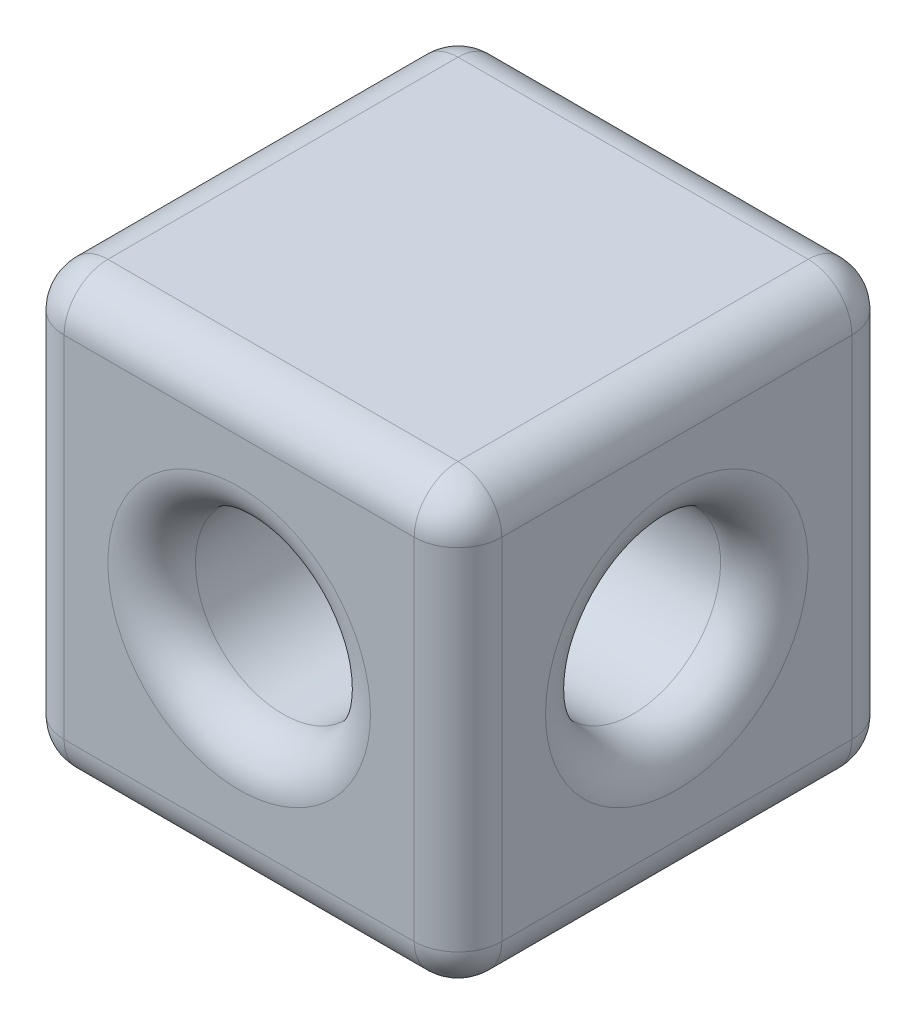
from build123d import *

# Parameters (mm, degrees)
ESQUISSE1_W             = 5
ESQUISSE1_H             = 5
ESQUISSE1_R             = 1
BOSS_EXTRU_1_DEPTH      = 5
ESQUISSE2_R             = 1
ENL_V_MAT_EXTRU_1_DEPTH = 10
CONG_1_R                = 0.5


with BuildPart() as part:
    # Esquisse1 → Boss.-Extru.1 (new body)
    with BuildSketch(Plane.XY):
        Rectangle(ESQUISSE1_W, ESQUISSE1_H)
        Circle(ESQUISSE1_R, mode=Mode.SUBTRACT)
    extrude(amount=BOSS_EXTRU_1_DEPTH)

    # Esquisse2 → Enlèv. mat.-Extru.1 (cut)
    with BuildSketch(Plane(origin=(2.5, 0, 0), x_dir=(0, 0, -1), z_dir=(1, 0, 0))):
        with Locations((-2.5, 0)):
            Circle(ESQUISSE2_R)
    extrude(amount=-ENL_V_MAT_EXTRU_1_DEPTH, mode=Mode.SUBTRACT)

    # Congé1
    cong_1_edges = [part.edges().sort_by_distance(p)[0] for p in [
        (-2.5, 0, 5),
        (-1, 0, 0),
        (-1, 0, 5),
        (0, -2.5, 5),
        (-2.5, 0, 3.5),
        (2.5, 0, 3.5),
        (2.5, 0, 5),
        (0, -2.5, 0),
        (-2.5, 0, 0),
        (0, 2.5, 0),
        (2.5, 0, 0),
        (0, 2.5, 5),
        (2.5, -2.5, 2.5),
        (-2.5, -2.5, 2.5),
        (-2.5, 2.5, 2.5),
        (2.5, 2.5, 2.5),
    ]]
    fillet(cong_1_edges, radius=CONG_1_R)


solid = part.part
